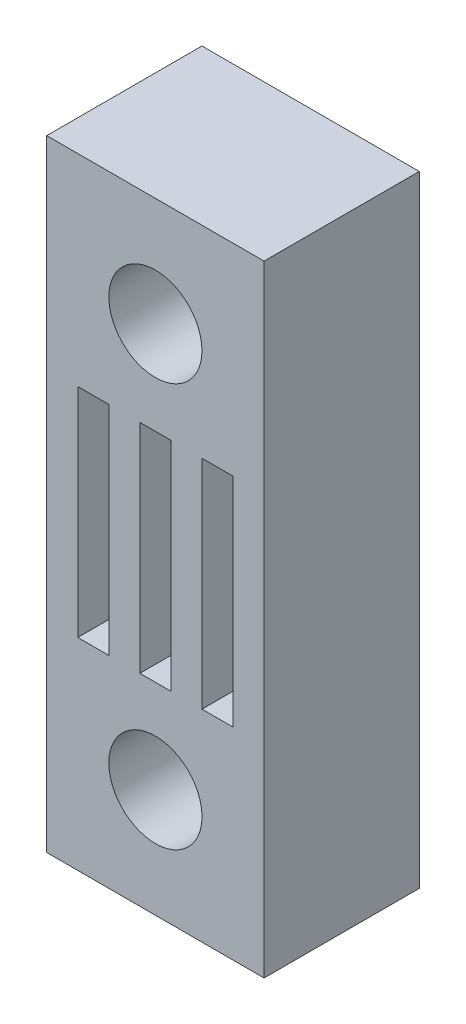
from build123d import *

# Parameters (mm, degrees)
SKETCH1_W           = 7
SKETCH1_H           = 20
SKETCH1_R           = 1.5
SKETCH1_W_2         = 1
SKETCH1_H_2         = 7
BOSS_EXTRUDE1_DEPTH = 5


with BuildPart() as part:
    # Sketch1 → Boss-Extrude1 (new body)
    with BuildSketch(Plane.XY):
        with Locations((3.5, 10)):
            Rectangle(SKETCH1_W, SKETCH1_H)
        with Locations((3.5, 16.5)):
            Circle(SKETCH1_R, mode=Mode.SUBTRACT)
        with Locations((3.5, 3.5)):
            Circle(SKETCH1_R, mode=Mode.SUBTRACT)
        with Locations((1.5, 10)):
            Rectangle(SKETCH1_W_2, SKETCH1_H_2, mode=Mode.SUBTRACT)
        with Locations((3.5, 10)):
            Rectangle(SKETCH1_W_2, SKETCH1_H_2, mode=Mode.SUBTRACT)
        with Locations((5.5, 10)):
            Rectangle(SKETCH1_W_2, SKETCH1_H_2, mode=Mode.SUBTRACT)
    extrude(amount=BOSS_EXTRUDE1_DEPTH)


solid = part.part
